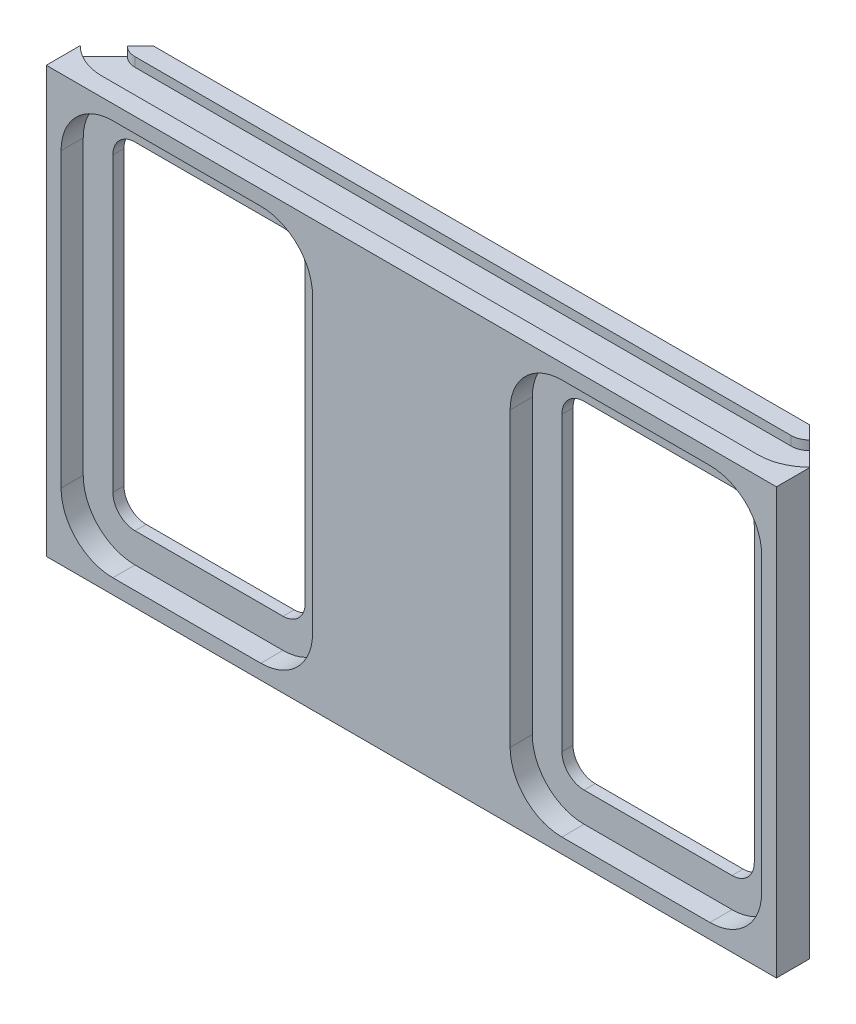
from build123d import *

# Parameters (mm, degrees)
SKETCH1_W           = 197.4
SKETCH1_H           = 115
BOSS_EXTRUDE1_DEPTH = 9
BOSS_EXTRUDE2_DEPTH = 10
CUT_EXTRUDE1_DEPTH  = 9
CUT_EXTRUDE2_DEPTH  = 6
CUT_EXTRUDE3_DEPTH  = 2.5


with BuildPart() as part:
    # Sketch1 → Boss-Extrude1 (new body)
    with BuildSketch(Plane.XY):
        with Locations((0, 19.485033023)):
            Rectangle(SKETCH1_W, SKETCH1_H)
    extrude(amount=BOSS_EXTRUDE1_DEPTH)

    # Sketch2 → Boss-Extrude2 (add)
    with BuildSketch(Plane(origin=(0, 76.985033023, 0), x_dir=(1, 0, 0), z_dir=(0, 1, 0))):
        Polygon((-88.7, 10), (88.7, 10), (98.7, 0), (-98.7, 0), align=None)
    extrude(amount=-BOSS_EXTRUDE2_DEPTH)

    # Sketch3 → Cut-Extrude1 (cut)
    with BuildSketch(Plane.XY.offset(9)):
        with BuildLine():
            Line((-80.7, 64.985033023), (-40.7, 64.985033023))
            ThreePointArc((-40.7, 64.985033023), (-36.457359313, 63.22767371), (-34.7, 58.985033023))
            Line((-34.7, 58.985033023), (-34.7, -20.014966977))
            ThreePointArc((-34.7, -20.014966977), (-36.457359313, -24.257607664), (-40.7, -26.014966977))
            Line((-40.7, -26.014966977), (-80.7, -26.014966977))
            ThreePointArc((-80.7, -26.014966977), (-84.942640687, -24.257607664), (-86.7, -20.014966977))
            Line((-86.7, -20.014966977), (-86.7, 58.985033023))
            ThreePointArc((-86.7, 58.985033023), (-84.942640687, 63.22767371), (-80.7, 64.985033023))
        make_face()
    cut_extrude1 = extrude(amount=-CUT_EXTRUDE1_DEPTH, mode=Mode.SUBTRACT)

    # Sketch4 → Cut-Extrude2 (cut)
    with BuildSketch(Plane.XY.offset(9)):
        with BuildLine():
            Line((-94.7, 58.985033023), (-94.7, -20.014966977))
            ThreePointArc((-94.7, -20.014966977), (-90.599494937, -29.914461914), (-80.7, -34.014966977))
            Line((-80.7, -34.014966977), (-40.7, -34.014966977))
            ThreePointArc((-40.7, -34.014966977), (-30.800505063, -29.914461914), (-26.7, -20.014966977))
            Line((-26.7, -20.014966977), (-26.7, 58.985033023))
            ThreePointArc((-26.7, 58.985033023), (-30.800505063, 68.88452796), (-40.7, 72.985033023))
            Line((-40.7, 72.985033023), (-80.7, 72.985033023))
            ThreePointArc((-80.7, 72.985033023), (-90.599494937, 68.88452796), (-94.7, 58.985033023))
        make_face()
    cut_extrude2 = extrude(amount=-CUT_EXTRUDE2_DEPTH, mode=Mode.SUBTRACT)

    # Mirror1: Cut-Extrude1, Cut-Extrude2 across plane
    add(cut_extrude1.mirror(Plane(origin=(0, 0, 0), x_dir=(0, 0, 1), z_dir=(1, 0, 0))), mode=Mode.SUBTRACT)
    add(cut_extrude2.mirror(Plane(origin=(0, 0, 0), x_dir=(0, 0, 1), z_dir=(1, 0, 0))), mode=Mode.SUBTRACT)

    # Sketch5 → Cut-Extrude3 (cut)
    with BuildSketch(Plane(origin=(0, 76.985033023, 0), x_dir=(1, 0, 0), z_dir=(0, 1, 0))):
        with BuildLine():
            Line((-88.7, 5), (88.7, 5))
            ThreePointArc((88.7, 5), (90.613417162, 5.380602337), (92.235533906, 6.464466094))
            Line((92.235533906, 6.464466094), (98.599494937, 0.100505063))
            ThreePointArc((98.599494937, 0.100505063), (94.057568053, -2.934313455), (88.7, -4))
            Line((88.7, -4), (-88.7, -4))
            ThreePointArc((-88.7, -4), (-94.057568053, -2.934313455), (-98.599494937, 0.100505063))
            Line((-98.599494937, 0.100505063), (-92.235533906, 6.464466094))
            ThreePointArc((-92.235533906, 6.464466094), (-90.613417162, 5.380602337), (-88.7, 5))
        make_face()
    extrude(amount=-CUT_EXTRUDE3_DEPTH, mode=Mode.SUBTRACT)


solid = part.part
